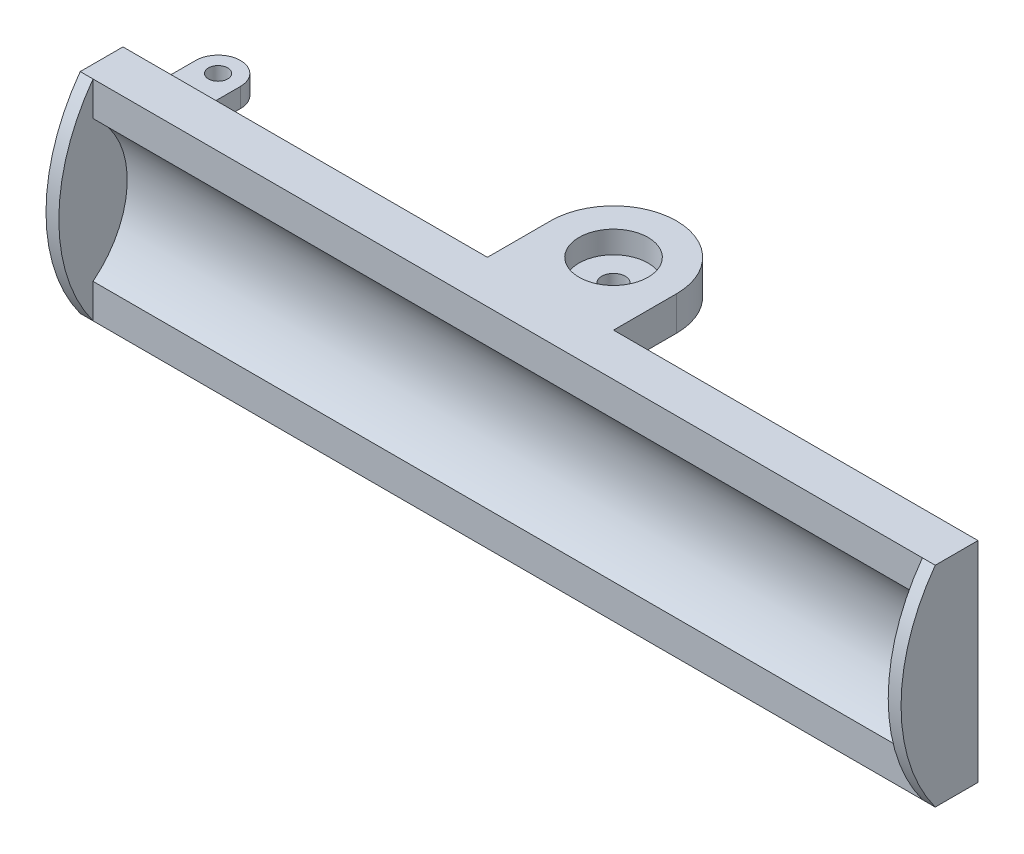
from build123d import *

# Parameters (mm, degrees)
BOSS_EXTRUDE1_DEPTH = 100
SKETCH3_R           = 14.75
SKETCH3_R_2         = 2.75
BOSS_EXTRUDE2_DEPTH = 8
SKETCH4_R           = 8.075
CUT_EXTRUDE1_DEPTH  = 5.2
BOSS_EXTRUDE5_START = 11
SKETCH6_R           = 2.25
BOSS_EXTRUDE5_DEPTH = 4.5
BOSS_EXTRUDE6_DEPTH = 3


with BuildPart() as part:
    # Sketch1 → Boss-Extrude1 (new body, symmetric)
    with BuildSketch(Plane.YZ):
        with BuildLine():
            Line((-24.5, 5), (-24.5, -5))
            Line((-24.5, -5), (24.5, -5))
            Line((24.5, -5), (24.5, 5))
            Line((24.5, 5), (16.492422502, 5))
            ThreePointArc((16.492422502, 5), (0, -3), (-16.492422502, 5))
            Line((-16.492422502, 5), (-24.5, 5))
        make_face()
    extrude(amount=BOSS_EXTRUDE1_DEPTH, both=True)

    # Sketch3 → Boss-Extrude2 (add)
    with BuildSketch(Plane.XZ.offset(24.5)):
        with Locations((0, -19.75)):
            Circle(SKETCH3_R)
        with Locations((0, -19.75)):
            Circle(SKETCH3_R_2, mode=Mode.SUBTRACT)
        with BuildLine():
            Line((-14.75, -5), (-14.75, -19.75))
            ThreePointArc((-14.75, -19.75), (-10.429825021, -9.320174976), (5e-09, -5))
            Line((5e-09, -5), (-14.75, -5))
        make_face()
        with BuildLine():
            ThreePointArc((5e-09, -5), (10.429825024, -9.320174979), (14.75, -19.75))
            Line((14.75, -19.75), (14.75, -5))
            Line((14.75, -5), (5e-09, -5))
        make_face()
    boss_extrude2 = extrude(amount=-BOSS_EXTRUDE2_DEPTH)

    # Sketch4 → Cut-Extrude1 (cut)
    with BuildSketch(Plane(origin=(0, -24.5, 0), x_dir=(-1, 0, 0), z_dir=(0, -1, 0))):
        with Locations((0, 19.75)):
            Circle(SKETCH4_R)
    cut_extrude1 = extrude(amount=-CUT_EXTRUDE1_DEPTH, mode=Mode.SUBTRACT)

    # Mirror1: Boss-Extrude2, Cut-Extrude1 across plane
    add(boss_extrude2.mirror(Plane(origin=(0, 0, 0), x_dir=(0, 0, 1), z_dir=(0, -1, 0))))
    add(cut_extrude1.mirror(Plane(origin=(0, 0, 0), x_dir=(0, 0, 1), z_dir=(0, -1, 0))), mode=Mode.SUBTRACT)

    # Sketch6 → Boss-Extrude5 (add)
    with BuildSketch(Plane(origin=(0, 0, 0), x_dir=(-1, 0, 0), z_dir=(0, -1, 0)).offset(BOSS_EXTRUDE5_START)):
        with BuildLine():
            Line((87.25, 19.75), (87.25, 5))
            Line((87.25, 5), (97.75, 5))
            Line((97.75, 5), (97.75, 19.75))
            ThreePointArc((97.75, 19.75), (92.5, 25), (87.25, 19.75))
        make_face()
        with Locations((92.5, 19.75)):
            Circle(SKETCH6_R, mode=Mode.SUBTRACT)
    boss_extrude5 = extrude(amount=BOSS_EXTRUDE5_DEPTH)

    # Mirror2: Boss-Extrude5 across plane
    add(boss_extrude5.mirror(Plane(origin=(0, 0, 0), x_dir=(0, 0, 1), z_dir=(0, -1, 0))))

    # Sketch7 → Boss-Extrude6 (add)
    with BuildSketch(Plane(origin=(-100, 0, 0), x_dir=(0, -1, 0), z_dir=(-1, 0, 0))):
        with BuildLine():
            Line((24.5, 5), (16.492422502, 5))
            ThreePointArc((16.492422502, 5), (0, -3), (-16.492422502, 5))
            Line((-16.492422502, 5), (-24.5, 5))
            Line((-24.5, 5), (-24.5, -5))
            Line((-24.5, -5), (24.5, -5))
            Line((24.5, -5), (24.5, 5))
        make_face()
        with BuildLine():
            Line((-16.492422502, 5), (16.492422502, 5))
            ThreePointArc((16.492422502, 5), (0, -3), (-16.492422502, 5))
        make_face()
        with BuildLine():
            ThreePointArc((24.5, 5), (0, 13), (-24.5, 5))
            Line((-24.5, 5), (-16.492422502, 5))
            Line((-16.492422502, 5), (16.492422502, 5))
            Line((16.492422502, 5), (24.5, 5))
        make_face()
    boss_extrude6 = extrude(amount=-BOSS_EXTRUDE6_DEPTH)

    # Mirror3: Boss-Extrude6 across plane
    add(boss_extrude6.mirror(Plane(origin=(0, 0, 0), x_dir=(0, 0, 1), z_dir=(1, 0, 0))))


solid = part.part
